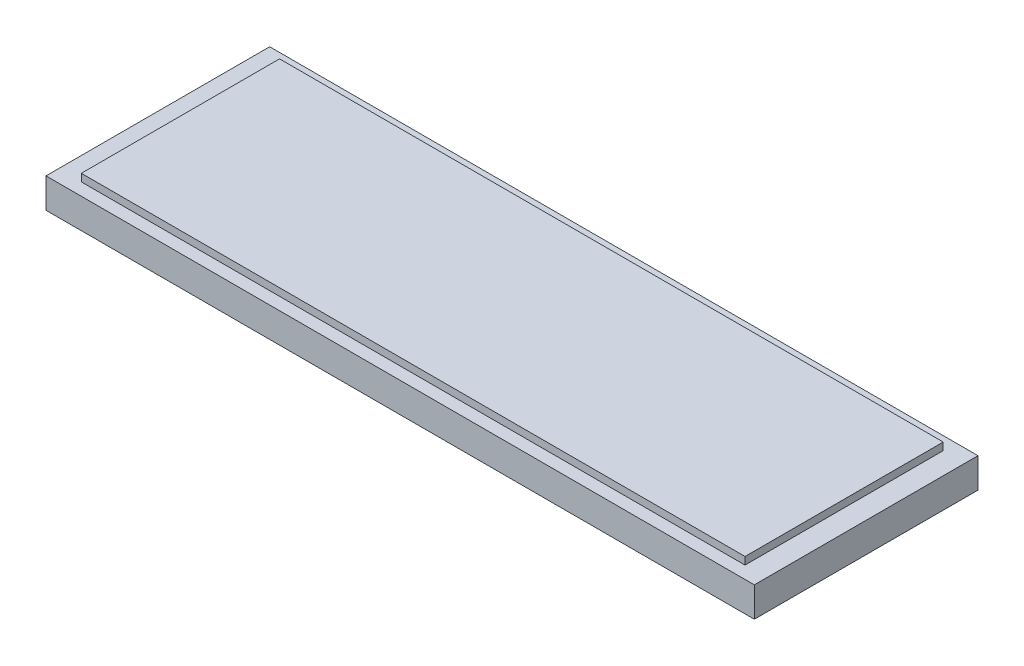
from build123d import *

# Parameters (mm, degrees)
SKETCH1_W           = 190
SKETCH1_H           = 60
BOSS_EXTRUDE1_DEPTH = 8
SKETCH2_W           = 178.027715847
SKETCH2_H           = 53.16732969
BOSS_EXTRUDE2_DEPTH = 2


with BuildPart() as part:
    # Sketch1 → Boss-Extrude1 (new body)
    with BuildSketch(Plane(origin=(0, 0, 0), x_dir=(1, 0, 0), z_dir=(0, 1, 0))):
        with Locations((-8.050847458, 13.020030817)):
            Rectangle(SKETCH1_W, SKETCH1_H)
    extrude(amount=BOSS_EXTRUDE1_DEPTH)

    # Sketch2 → Boss-Extrude2 (add)
    with BuildSketch(Plane(origin=(0, 8, 0), x_dir=(1, 0, 0), z_dir=(0, 1, 0))):
        with Locations((-7.900231793, 12.944722984)):
            Rectangle(SKETCH2_W, SKETCH2_H)
    extrude(amount=BOSS_EXTRUDE2_DEPTH)


solid = part.part
